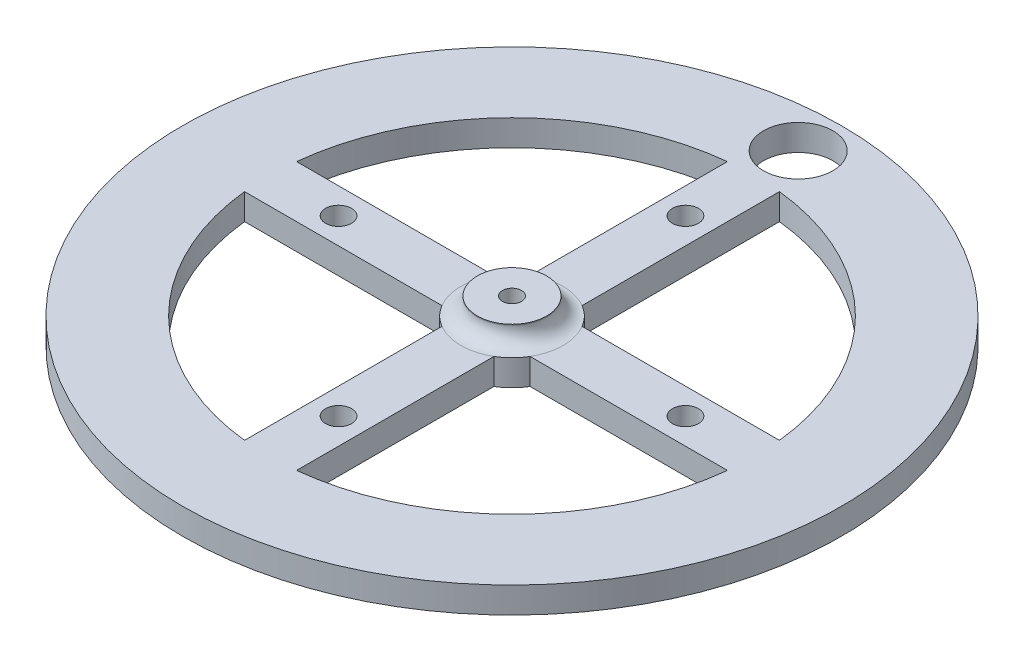
from build123d import *

# Parameters (mm, degrees)
CORTE_EXTRUS_O4_START  = -1
ESBO_O2_R              = 1.5
CORTE_EXTRUS_O4_DEPTH  = 7
CORTE_EXTRUS_O9_START  = -4
CORTE_EXTRUS_O9_DEPTH  = 7
PADR_OCIRCULAR1_COUNT  = 4
ESBO_O7_R              = 4
CORTE_EXTRUS_O10_DEPTH = 10


with BuildPart() as part:
    # Esboço1 → Revolução1 (revolve)
    with BuildSketch(Plane.XY):
        with BuildLine():
            Line((1.1, 5), (1.1, 0))
            Line((1.1, 0), (38, 0))
            Line((38, 0), (38, 3))
            Line((38, 3), (5.9, 3))
            ThreePointArc((5.9, 3), (4.556497116, 3.556497116), (4, 4.9))
            Line((4, 4.9), (4, 5))
            Line((4, 5), (1.1, 5))
        make_face()
    revolve(axis=Axis((0, 0, 0), (0, 1, 0)))

    # Esboço2 → Corte-extrusão4 (cut)
    with BuildSketch(Plane(origin=(0, 0, 0), x_dir=(1, 0, 0), z_dir=(0, 1, 0)).offset(CORTE_EXTRUS_O4_START)):
        with Locations((0, 20)):
            Circle(ESBO_O2_R)
    corte_extrus_o4 = extrude(amount=CORTE_EXTRUS_O4_DEPTH, mode=Mode.SUBTRACT)

    # Esboço6 → Corte-extrusão9 (cut)
    with BuildSketch(Plane(origin=(0, 3, 0), x_dir=(1, 0, 0), z_dir=(0, 1, 0)).offset(CORTE_EXTRUS_O9_START)):
        with BuildLine():
            Line((3, 27.838821814), (3, 5.080354318))
            ThreePointArc((3, 5.080354318), (4.171930009, 4.171930009), (5.080354318, 3))
            Line((5.080354318, 3), (27.838821814, 3))
            ThreePointArc((27.838821814, 3), (19.798989873, 19.798989873), (3, 27.838821814))
        make_face()
    corte_extrus_o9 = extrude(amount=CORTE_EXTRUS_O9_DEPTH, mode=Mode.SUBTRACT)

    # PadrãoCircular1: Corte-extrusão4, Corte-extrusão9 ×4 about axis
    padr_ocircular1_axis = Axis((0, 0, 0), (0, 1, 0))
    for i in range(1, PADR_OCIRCULAR1_COUNT):
        add(corte_extrus_o4.rotate(padr_ocircular1_axis, i * 360 / PADR_OCIRCULAR1_COUNT), mode=Mode.SUBTRACT)
        add(corte_extrus_o9.rotate(padr_ocircular1_axis, i * 360 / PADR_OCIRCULAR1_COUNT), mode=Mode.SUBTRACT)

    # Esboço7 → Corte-extrusão10 (cut)
    with BuildSketch(Plane(origin=(0, 3, 0), x_dir=(1, 0, 0), z_dir=(0, 1, 0))):
        with Locations((0, 33)):
            Circle(ESBO_O7_R)
    extrude(amount=-CORTE_EXTRUS_O10_DEPTH, mode=Mode.SUBTRACT)


solid = part.part
